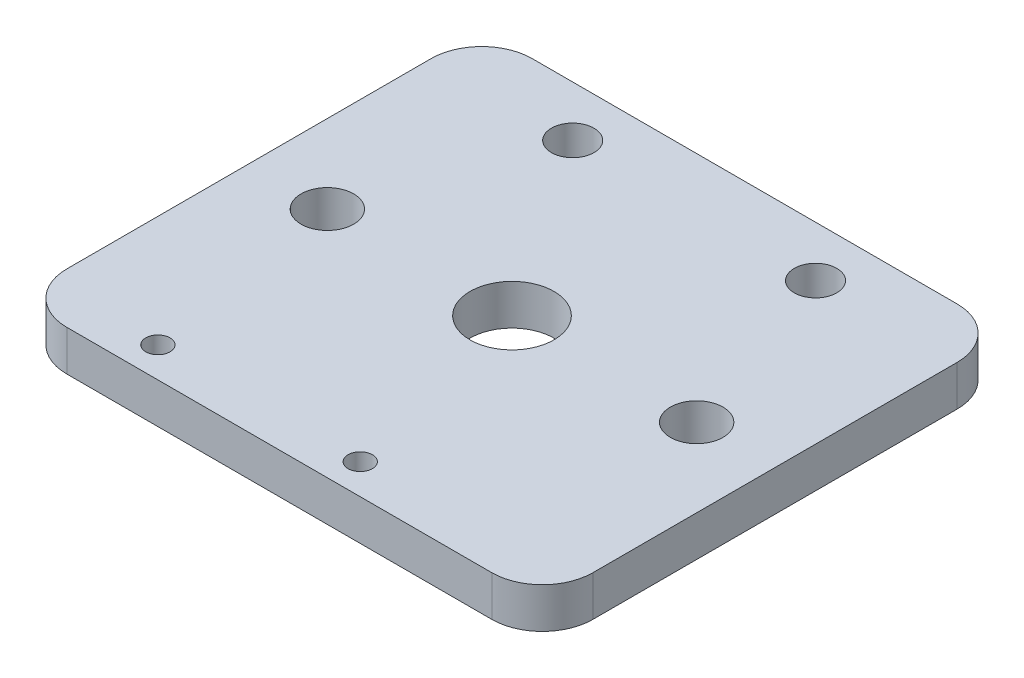
from build123d import *

# Parameters (mm, degrees)
SKETCH_1_W            = 52
SKETCH_1_H            = 46
SKETCH_1_R            = 2.6
SKETCH_1_R_2          = 4.15
EXTRUDE_436_DEPTH     = 4
SKETCH_4_R            = 2.1
CUT_EXTRUDE_686_DEPTH = 5
SKETCH_6_R            = 2.1
EXTRUDE_1_DEPTH       = 4
SKETCH_7_R            = 1.2
CUT_EXTRUDE_1_DEPTH   = 5
SKETCH_8_W            = 29.384652785
SKETCH_8_H            = 46
EXTRUDE_2_DEPTH       = 4
SKETCH_9_W            = 29.384652785
SKETCH_9_H            = 46
CUT_EXTRUDE_2_DEPTH   = 5
FILLET_1_R            = 5


with BuildPart() as part:
    # 草图1 → Extrude 436 (new body)
    with BuildSketch(Plane(origin=(0, 0, 0), x_dir=(1, 0, 0), z_dir=(0, 1, 0))):
        Rectangle(SKETCH_1_W, SKETCH_1_H)
        with Locations((-18.25, 0)):
            Circle(SKETCH_1_R, mode=Mode.SUBTRACT)
        with Locations((18.25, 0)):
            Circle(SKETCH_1_R, mode=Mode.SUBTRACT)
        Circle(SKETCH_1_R_2, mode=Mode.SUBTRACT)
    extrude(amount=EXTRUDE_436_DEPTH)

    # 草图4 → Cut-Extrude 686 (cut, through all)
    with BuildSketch(Plane(origin=(0, 4, 0), x_dir=(1, 0, 0), z_dir=(0, 1, 0))):
        with Locations((-12, 18)):
            Circle(SKETCH_4_R)
        with Locations((12, 18)):
            Circle(SKETCH_4_R)
        with Locations((12, -18)):
            Circle(SKETCH_4_R)
        with Locations((-12, -18)):
            Circle(SKETCH_4_R)
    extrude(amount=-CUT_EXTRUDE_686_DEPTH, mode=Mode.SUBTRACT)

    # 草图6 → 凸台-拉伸1 (add)
    with BuildSketch(Plane(origin=(0, 4, 0), x_dir=(1, 0, 0), z_dir=(0, 1, 0))):
        with Locations((-12, -18)):
            Circle(SKETCH_6_R)
        with Locations((12, -18)):
            Circle(SKETCH_6_R)
    extrude(amount=-EXTRUDE_1_DEPTH)

    # 草图7 → 切除-拉伸1 (cut, through all)
    with BuildSketch(Plane(origin=(0, 4, 0), x_dir=(1, 0, 0), z_dir=(0, 1, 0))):
        with Locations((5, -20)):
            Circle(SKETCH_7_R)
        with Locations((-15, -20)):
            Circle(SKETCH_7_R)
    extrude(amount=-CUT_EXTRUDE_1_DEPTH, mode=Mode.SUBTRACT)

    # 草图8 → 凸台-拉伸2 (add)
    with BuildSketch(Plane.XZ):
        with Locations((40.692326393, 0)):
            Rectangle(SKETCH_8_W, SKETCH_8_H)
    extrude(amount=-EXTRUDE_2_DEPTH)

    # 草图9 → 切除-拉伸2 (cut, through all)
    with BuildSketch(Plane(origin=(0, 4, 0), x_dir=(1, 0, 0), z_dir=(0, 1, 0))):
        with Locations((40.692326393, 0)):
            Rectangle(SKETCH_9_W, SKETCH_9_H)
    extrude(amount=-CUT_EXTRUDE_2_DEPTH, mode=Mode.SUBTRACT)

    # 圆角1
    fillet_1_edges = [part.edges().sort_by_distance(p)[0] for p in [
        (-26, 2, 23),
        (-26, 2, -23),
        (26, 2, 23),
        (26, 2, -23),
    ]]
    fillet(fillet_1_edges, radius=FILLET_1_R)


solid = part.part
